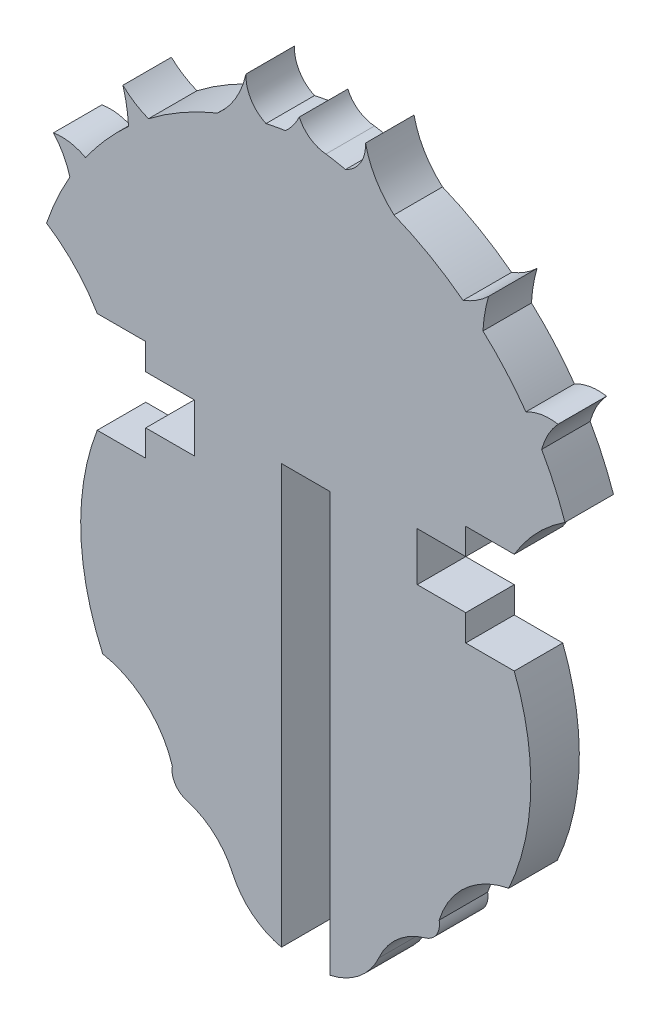
from build123d import *

# Parameters (mm, degrees)
BOSS_EXTRUDE2_DEPTH = 1.524


with BuildPart() as part:
    # Sketch1 → Boss-Extrude2 (new body)
    with BuildSketch(Plane.XY):
        with BuildLine():
            Line((22.439190696, 2.281072115), (22.439190696, 15.440411119))
            Line((22.439190696, 15.440411119), (23.963190696, 15.440411119))
            Line((23.963190696, 15.440411119), (23.963190696, 2.281072115))
            ThreePointArc((23.963190696, 2.281072115), (24.875976359, 2.718444333), (25.496797873, 3.517852096))
            ThreePointArc((25.496797873, 3.517852096), (26.079485641, 4.314676532), (26.944327918, 4.790598847))
            ThreePointArc((26.944327918, 4.790598847), (27.306638474, 5.053990144), (27.391790825, 5.493754843))
            ThreePointArc((27.391790825, 5.493754843), (28.213802596, 6.77713145), (29.579242724, 7.454133758))
            ThreePointArc((29.579242724, 7.454133758), (30.268025744, 10.435749579), (29.751585716, 13.451996362))
            Line((29.751585716, 13.451996362), (28.227585716, 13.451996362))
            Line((28.227585716, 13.451996362), (28.227585716, 14.277496362))
            Line((28.227585716, 14.277496362), (26.703585716, 14.277496362))
            Line((26.703585716, 14.277496362), (26.703585716, 15.801496362))
            Line((26.703585716, 15.801496362), (28.227585716, 15.801496362))
            Line((28.227585716, 15.801496362), (28.227585716, 16.626996362))
            Line((28.227585716, 16.626996362), (29.751585716, 16.626996362))
            ThreePointArc((29.751585716, 16.626996362), (30.450938942, 17.551968079), (31.344559642, 18.290960401))
            ThreePointArc((31.344559642, 18.290960401), (31.016414864, 19.117764263), (30.611916517, 19.910017196))
            ThreePointArc((30.611916517, 19.910017196), (30.812764797, 20.413642259), (31.127845897, 20.854892911))
            ThreePointArc((31.127845897, 20.854892911), (30.608483418, 20.85451221), (30.117641351, 20.684772426))
            ThreePointArc((30.117641351, 20.684772426), (29.483865735, 21.483760637), (28.767611914, 22.209731818))
            ThreePointArc((28.767611914, 22.209731818), (28.825967468, 22.730638245), (28.945134545, 23.241077355))
            ThreePointArc((28.945134545, 23.241077355), (28.568640605, 22.947137357), (28.142874774, 22.730638245))
            ThreePointArc((28.142874774, 22.730638245), (27.099472832, 23.422587859), (25.973692104, 23.970401362))
            ThreePointArc((25.973692104, 23.970401362), (25.40453187, 24.652580061), (25.079145794, 25.479281369))
            ThreePointArc((25.079145794, 25.479281369), (24.923162133, 24.865841557), (24.450537029, 24.444813273))
            ThreePointArc((24.450537029, 24.444813273), (24.144286047, 24.507151138), (23.836139674, 24.559319007))
            ThreePointArc((23.836139674, 24.559319007), (23.336074732, 24.737274916), (22.998556028, 25.146926447))
            ThreePointArc((22.998556028, 25.146926447), (22.81061569, 24.832363061), (22.566241718, 24.559319007))
            ThreePointArc((22.566241718, 24.559319007), (22.258095346, 24.507151138), (21.951844363, 24.444813273))
            ThreePointArc((21.951844363, 24.444813273), (21.47921926, 24.865841557), (21.323235599, 25.479281369))
            ThreePointArc((21.323235599, 25.479281369), (20.997849523, 24.652580061), (20.428689288, 23.970401362))
            ThreePointArc((20.428689288, 23.970401362), (19.302908561, 23.422587859), (18.259506619, 22.730638245))
            ThreePointArc((18.259506619, 22.730638245), (17.833740787, 22.947137357), (17.457246848, 23.241077355))
            ThreePointArc((17.457246848, 23.241077355), (17.576413925, 22.730638245), (17.634769478, 22.209731818))
            ThreePointArc((17.634769478, 22.209731818), (16.918515657, 21.483760637), (16.284740042, 20.684772426))
            ThreePointArc((16.284740042, 20.684772426), (15.793897974, 20.85451221), (15.274535496, 20.854892911))
            ThreePointArc((15.274535496, 20.854892911), (15.589616595, 20.413642259), (15.790464876, 19.910017196))
            ThreePointArc((15.790464876, 19.910017196), (15.385966529, 19.117764263), (15.05782175, 18.290960401))
            ThreePointArc((15.05782175, 18.290960401), (15.951442451, 17.551968079), (16.650795677, 16.626996362))
            Line((16.650795677, 16.626996362), (18.174795677, 16.626996362))
            Line((18.174795677, 16.626996362), (18.174795677, 15.801496362))
            Line((18.174795677, 15.801496362), (19.698795677, 15.801496362))
            Line((19.698795677, 15.801496362), (19.698795677, 14.277496362))
            Line((19.698795677, 14.277496362), (18.174795677, 14.277496362))
            Line((18.174795677, 14.277496362), (18.174795677, 13.451996362))
            Line((18.174795677, 13.451996362), (16.650795677, 13.451996362))
            ThreePointArc((16.650795677, 13.451996362), (16.134355649, 10.435749579), (16.823138669, 7.454133758))
            ThreePointArc((16.823138669, 7.454133758), (18.188578797, 6.77713145), (19.010590568, 5.493754843))
            ThreePointArc((19.010590568, 5.493754843), (19.095742919, 5.053990144), (19.458053474, 4.790598847))
            ThreePointArc((19.458053474, 4.790598847), (20.322895752, 4.314676532), (20.905583519, 3.517852096))
            ThreePointArc((20.905583519, 3.517852096), (21.526405033, 2.718444333), (22.439190696, 2.281072115))
        make_face()
    extrude(amount=BOSS_EXTRUDE2_DEPTH)


solid = part.part
